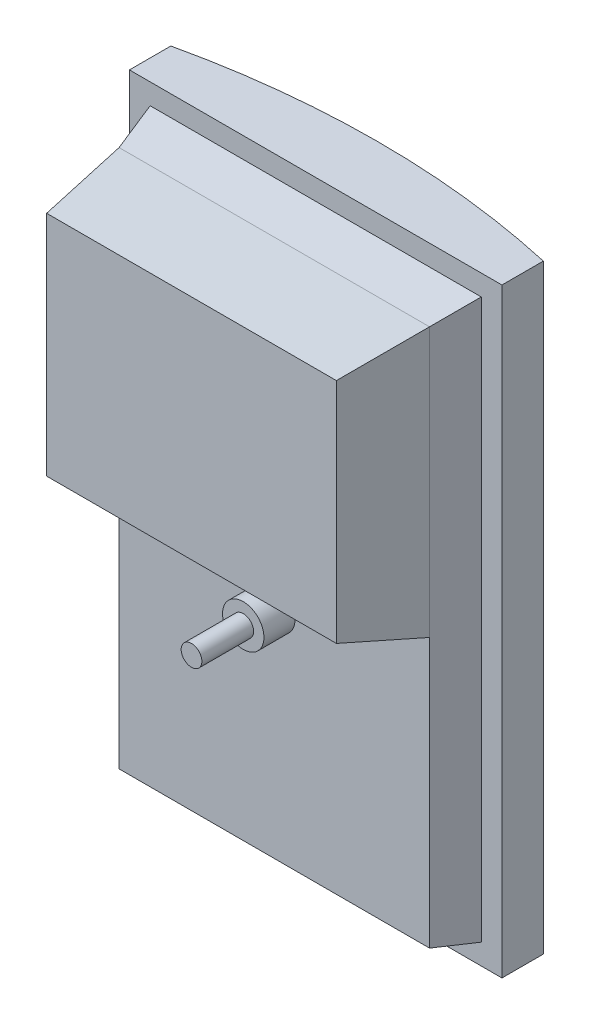
from build123d import *

# Parameters (mm, degrees)
BOSS_EXTRUDE1_DEPTH      = 28.575
BOSS_EXTRUDE1_DEPTH_BACK = 63.5
SKETCH4_W                = 50.8
SKETCH4_H                = 85.725
SKETCH5_W                = 47.625
SKETCH5_H                = 82.55
SKETCH7_W                = 47.625
SKETCH7_H                = 41.275
SKETCH6_W                = 44.45
SKETCH6_H                = 34.925
SKETCH8_R                = 1.5875
BOSS_EXTRUDE2_DEPTH      = 12.7
SKETCH10_R               = 3.175
BOSS_EXTRUDE3_DEPTH      = 4.7625


with BuildPart() as part:
    # Sketch1 → Boss-Extrude1 (new body, two sides)
    with BuildSketch(Plane(origin=(0, 0, 0), x_dir=(1, 0, 0), z_dir=(0, 1, 0))) as boss_extrude1_sk:
        with BuildLine():
            Line((-28.575, -3.175), (-28.575, -9.525))
            Line((-28.575, -9.525), (28.575, -9.525))
            Line((28.575, -9.525), (28.575, -3.175))
            ThreePointArc((28.575, -3.175), (0, 0), (-28.575, -3.175))
        make_face()
    extrude(amount=BOSS_EXTRUDE1_DEPTH)
    extrude(boss_extrude1_sk.sketch, amount=-BOSS_EXTRUDE1_DEPTH_BACK)

    # Sketch3 → Revolve1 (revolve)
    with BuildSketch(Plane(origin=(0, 0, 0), x_dir=(0, 0, -1), z_dir=(1, 0, 0)), mode=Mode.PRIVATE) as revolve1_sk:
        Polygon((-3.175, 15.875), (-3.175, 0), (8.52780731, 0), (8.52780731, 6.35), (9.525, 7.284627481), (9.525, 8.872127481), (6.35, 9.650285268), (5.215006498, 12.7), align=None)
    revolve(revolve1_sk.sketch.rotate(Axis((0, 0, 3.175), (0, 0, -1)), 90), axis=Axis((0, 0, 3.175), (0, 0, -1)))  # turned: the seam where the file's is

    # Sketch4 → Loft1 section 0
    with BuildSketch(Plane.XY.offset(9.525)):
        with Locations((0, -17.4625)):
            Rectangle(SKETCH4_W, SKETCH4_H)
    # Sketch5 → Loft1 section 1
    with BuildSketch(Plane.XY.offset(15.875)):
        with Locations((0, -17.4625)):
            Rectangle(SKETCH5_W, SKETCH5_H)
    loft()

    # Sketch7 → Loft2 section 0
    with BuildSketch(Plane.XY.offset(15.875)):
        with Locations((0, 3.175)):
            Rectangle(SKETCH7_W, SKETCH7_H)
    # Sketch6 → Loft2 section 1
    with BuildSketch(Plane.XY.offset(28.575)):
        with Locations((0, 4.7625)):
            Rectangle(SKETCH6_W, SKETCH6_H)
    loft()

    # Sketch8 → Boss-Extrude2 (add)
    with BuildSketch(Plane.XY.offset(15.875)):
        with Locations((0, -25.4)):
            Circle(SKETCH8_R)
    extrude(amount=BOSS_EXTRUDE2_DEPTH)

    # Sketch10 → Boss-Extrude3 (add)
    with BuildSketch(Plane.XY.offset(15.875)):
        with Locations(Location((0, -25.4, 0), (0, 0, 180))):  # turned: the seam where the file's is
            Circle(SKETCH10_R)
    extrude(amount=BOSS_EXTRUDE3_DEPTH)


solid = part.part
